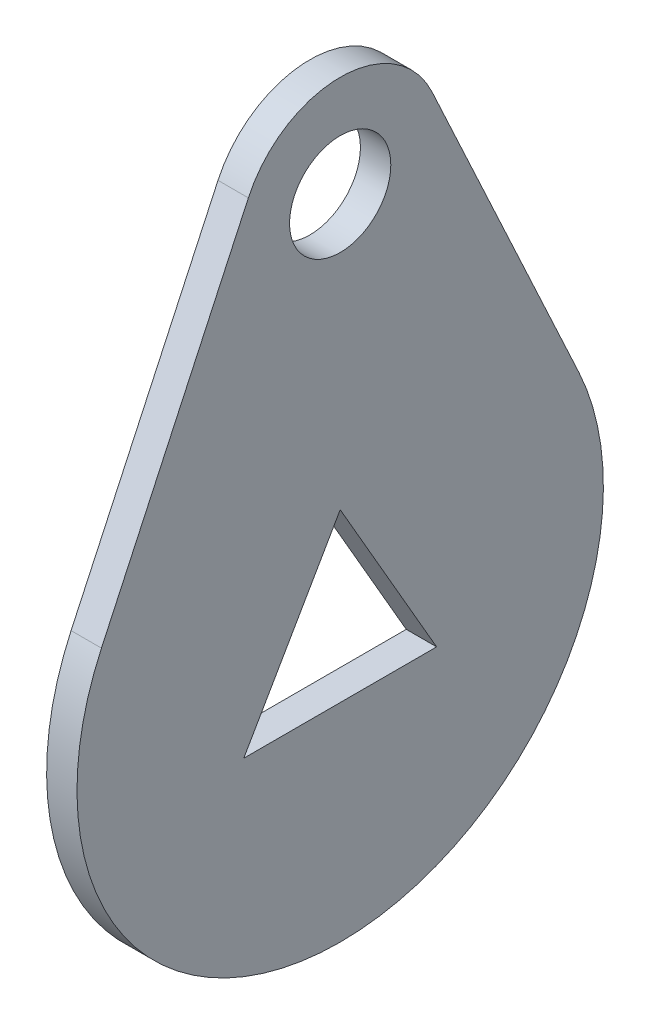
from build123d import *

# Parameters (mm, degrees)
SKETCH1_R           = 2.5
BOSS_EXTRUDE1_DEPTH = 1.5


with BuildPart() as part:
    # Sketch1 → Boss-Extrude1 (new body)
    with BuildSketch(Plane(origin=(0, 0, 0), x_dir=(0, 0, -1), z_dir=(1, 0, 0))):
        with BuildLine():
            Line((-11.791470696, 5.473684211), (-4.535181037, 21.105263158))
            ThreePointArc((-4.535181037, 21.105263158), (0, 24), (4.535181037, 21.105263158))
            Line((4.535181037, 21.105263158), (11.791470696, 5.473684211))
            ThreePointArc((11.791470696, 5.473684211), (0, -13), (-11.791470696, 5.473684211))
        make_face()
        with Locations((0, 19)):
            Circle(SKETCH1_R, mode=Mode.SUBTRACT)
        Polygon((4.763139721, -2.75), (-4.763139721, -2.75), (0, 5.5), align=None, mode=Mode.SUBTRACT)
    extrude(amount=BOSS_EXTRUDE1_DEPTH)


solid = part.part
